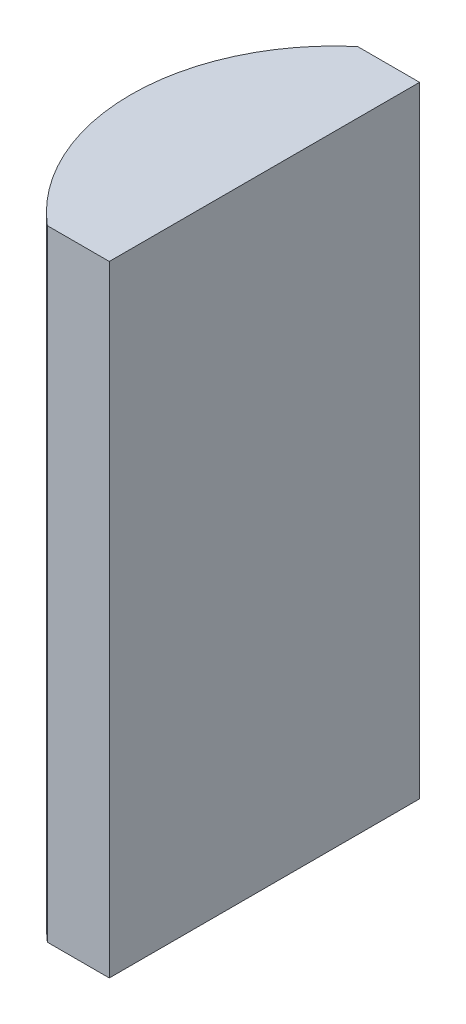
from build123d import *

# Parameters (mm, degrees)
EXTRUDE_1_DEPTH = 20


with BuildPart() as part:
    # 草图1 → 凸台-拉伸1 (new body)
    with BuildSketch(Plane(origin=(0, 0, 0), x_dir=(1, 0, 0), z_dir=(0, 1, 0))):
        with BuildLine():
            Line((0.108605696, 5), (2.105204335, 5))
            Line((2.105204335, 5), (2.105204335, -5))
            Line((2.105204335, -5), (0.108605696, -5))
            ThreePointArc((0.108605696, -5), (-2.204795665, 0), (0.108605696, 5))
        make_face()
    extrude(amount=EXTRUDE_1_DEPTH)


solid = part.part
